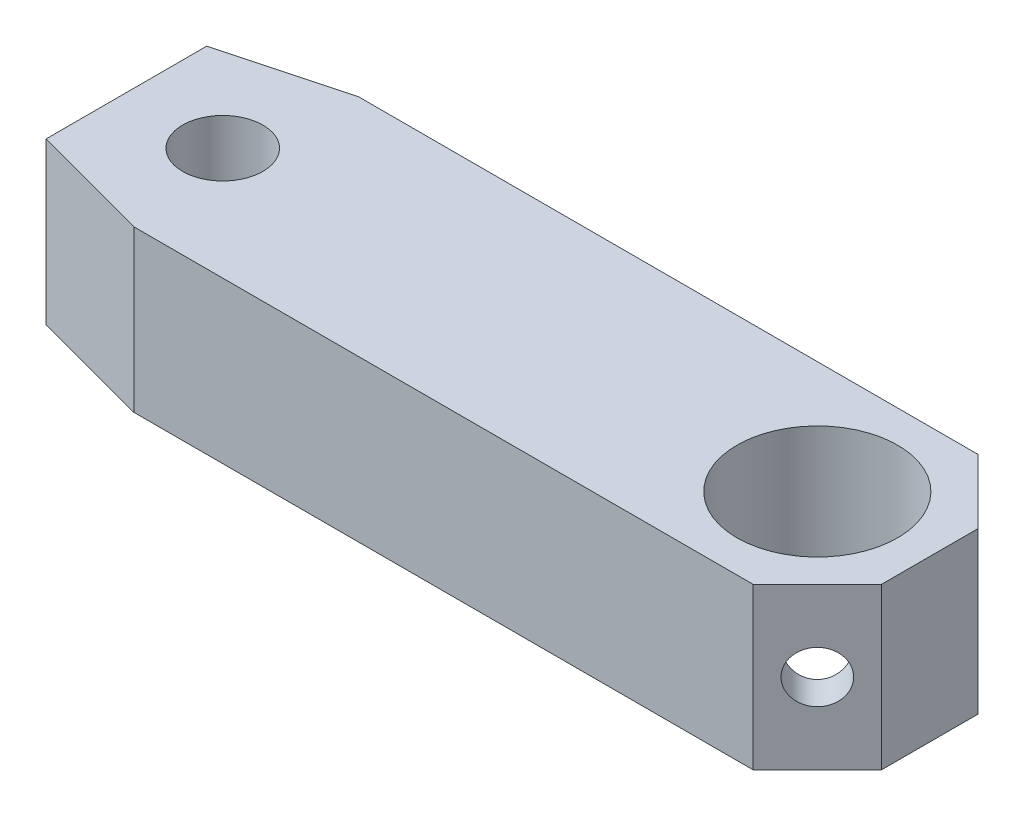
from build123d import *

# Parameters (mm, degrees)
BLOCK_R                = 2.5
BOSS_EXTRUDE1_DEPTH    = 5
M3_TAPPED_HOLE1_D      = 2.5
M2_TAPPED_HOLE1_REACH  = 23.797
M2_TAPPED_HOLE1_BORE_R = 0.8


with BuildPart() as part:
    # block → Boss-Extrude1 (new body)
    with BuildSketch(Plane(origin=(0, 0, 0), x_dir=(1, 0, 0), z_dir=(0, 1, 0))):
        Polygon((0.732050808, 3.5), (20, 3.5), (22, 1.5), (22, -1.5), (20, -3.5), (0.732050808, -3.5), (-3, -2.5), (-3, 2.5), align=None)
        with Locations(Location((18.5, 0, 0), (0, 0, 270))):
            Circle(BLOCK_R, mode=Mode.SUBTRACT)
    extrude(amount=-BOSS_EXTRUDE1_DEPTH)

    # M3 Tapped Hole1 (through all)
    with Locations(Plane(origin=(0, 0, 0), x_dir=(1, 0, 0), z_dir=(0, 1, 0))):
        with Locations((0, 0)):
            Hole(M3_TAPPED_HOLE1_D / 2)

    # M2 Tapped Hole1 bore → M2 Tapped Hole1 (cut, up to next)
    with BuildSketch(Plane(origin=(11.75, 0, -11.75), x_dir=(-0.7071067811865465, 0, -0.7071067811865486), z_dir=(0.7071067811865486, 0, -0.7071067811865465)), mode=Mode.PRIVATE) as m2_tapped_hole1_sk1:
        with Locations((-13.081475452, -2.5)):
            Circle(M2_TAPPED_HOLE1_BORE_R)
    m2_tapped_hole1_tool1 = extrude(m2_tapped_hole1_sk1.sketch, amount=-M2_TAPPED_HOLE1_REACH, mode=Mode.PRIVATE) & part.part
    m2_tapped_hole1 = m2_tapped_hole1_tool1.solids().sort_by_distance((21, -2.5, -2.5))[0]
    add(m2_tapped_hole1, mode=Mode.SUBTRACT)

    # Mirror1: M2 Tapped Hole1 across plane
    add(m2_tapped_hole1.mirror(Plane.XY), mode=Mode.SUBTRACT)


solid = part.part
